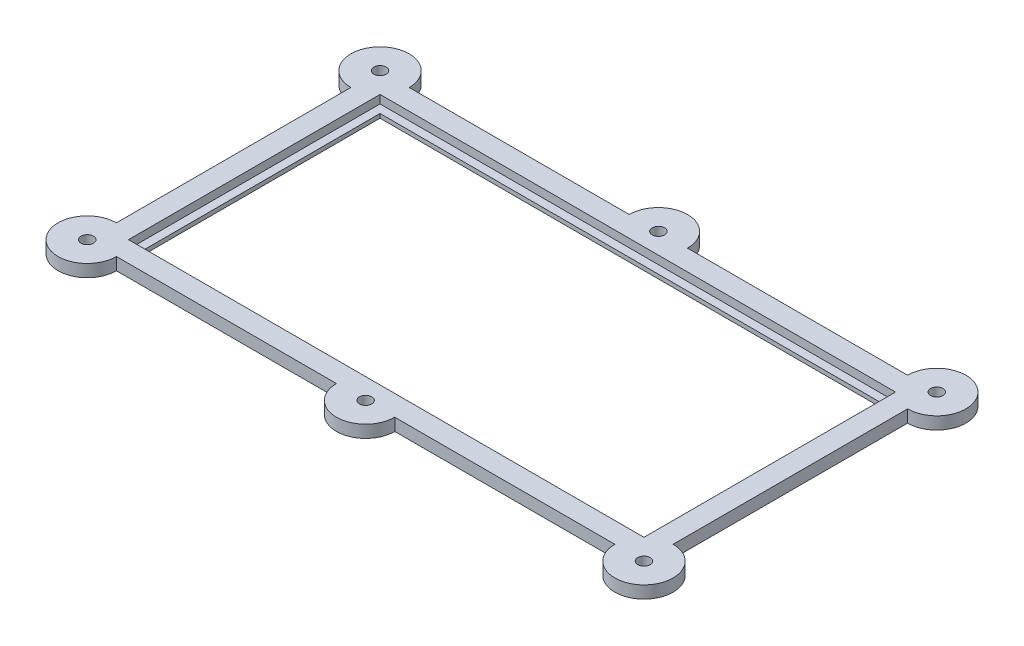
from build123d import *

# Parameters (mm, degrees)
SKETCH1_W               = 67.5
SKETCH1_H               = 35.5
SKETCH1_W_2             = 62.5
SKETCH1_H_2             = 30.5
BOSS_EXTRUDE1_DEPTH     = 1
SKETCH2_W               = 67.5
SKETCH2_H               = 35.5
SKETCH2_W_2             = 60.5
SKETCH2_H_2             = 28.5
BOSS_EXTRUDE2_DEPTH     = 0.5
SKETCH3_R               = 3.535533906
BOSS_EXTRUDE3_DEPTH     = 1.5
SKETCH4_R               = 0.75
CUT_EXTRUDE1_DEPTH      = 1
CUT_EXTRUDE1_DEPTH_BACK = 2.5


with BuildPart() as part:
    # Sketch1 → Boss-Extrude1 (new body)
    with BuildSketch(Plane(origin=(0, 0, 0), x_dir=(1, 0, 0), z_dir=(0, 1, 0))):
        Rectangle(SKETCH1_W, SKETCH1_H)
        Rectangle(SKETCH1_W_2, SKETCH1_H_2, mode=Mode.SUBTRACT)
    extrude(amount=BOSS_EXTRUDE1_DEPTH)

    # Sketch2 → Boss-Extrude2 (add)
    with BuildSketch(Plane.XZ):
        Rectangle(SKETCH2_W, SKETCH2_H)
        Rectangle(SKETCH2_W_2, SKETCH2_H_2, mode=Mode.SUBTRACT)
    extrude(amount=BOSS_EXTRUDE2_DEPTH)

    # Sketch3 → Boss-Extrude3 (add)
    with BuildSketch(Plane(origin=(0, 1, 0), x_dir=(1, 0, 0), z_dir=(0, 1, 0))):
        with Locations((-33.75, 17.75)):
            Circle(SKETCH3_R)
        with Locations((33.75, 17.75)):
            Circle(SKETCH3_R)
        with Locations((33.75, -17.75)):
            Circle(SKETCH3_R)
        with Locations((-33.75, -17.75)):
            Circle(SKETCH3_R)
        with BuildLine():
            Line((-3.535533906, 17.75), (3.535533906, 17.75))
            ThreePointArc((3.535533906, 17.75), (0, 21.285533906), (-3.535533906, 17.75))
        make_face()
        with BuildLine():
            Line((-3.535533906, -17.75), (3.535533906, -17.75))
            ThreePointArc((3.535533906, -17.75), (0, -21.285533906), (-3.535533906, -17.75))
        make_face()
    extrude(amount=-BOSS_EXTRUDE3_DEPTH)

    # Sketch4 → Cut-Extrude1 (cut, two sides)
    with BuildSketch(Plane(origin=(0, 1, 0), x_dir=(1, 0, 0), z_dir=(0, 1, 0))) as cut_extrude1_sk:
        with Locations((-33.75, 17.75)):
            Circle(SKETCH4_R)
        with Locations((33.75, 17.75)):
            Circle(SKETCH4_R)
        with Locations((33.75, -17.75)):
            Circle(SKETCH4_R)
        with Locations((-33.75, -17.75)):
            Circle(SKETCH4_R)
        with Locations((0, 17.75)):
            Circle(SKETCH4_R)
        with Locations((0, -17.75)):
            Circle(SKETCH4_R)
    extrude(amount=CUT_EXTRUDE1_DEPTH, mode=Mode.SUBTRACT)
    extrude(cut_extrude1_sk.sketch, amount=-CUT_EXTRUDE1_DEPTH_BACK, mode=Mode.SUBTRACT)


solid = part.part
